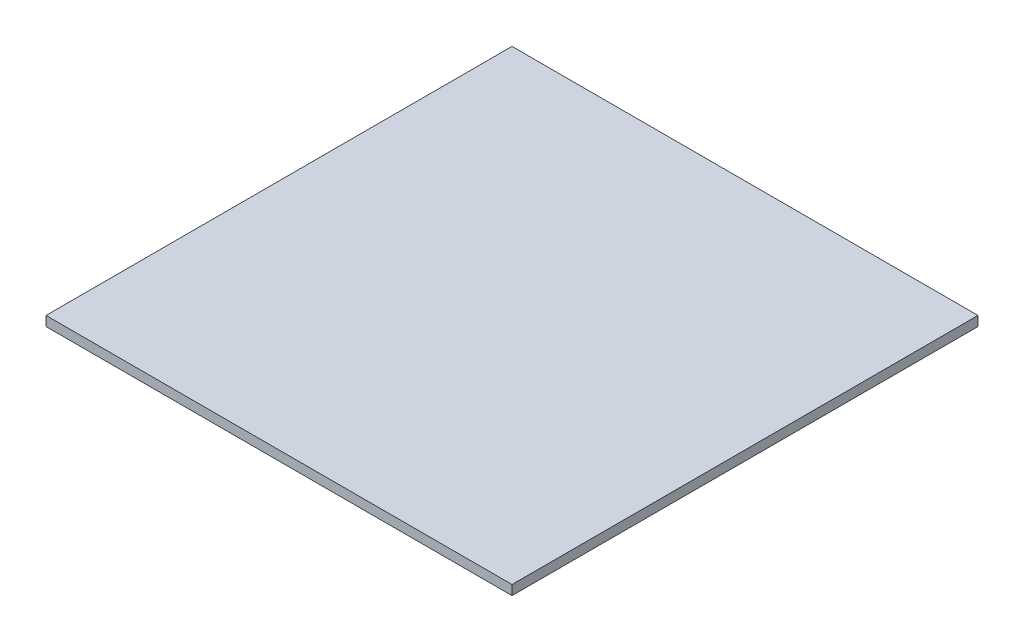
from build123d import *

# Parameters (mm, degrees)
SKETCH2_R           = 60
BOSS_EXTRUDE1_DEPTH = 36
SKETCH3_W           = 290
SKETCH3_H           = 290
BOSS_EXTRUDE2_DEPTH = 6


with BuildPart() as part:
    # Sketch2 → Boss-Extrude1 (new body)
    with BuildSketch(Plane(origin=(0, 0, 0), x_dir=(1, 0, 0), z_dir=(0, 1, 0))):
        Circle(SKETCH2_R)
    extrude(amount=BOSS_EXTRUDE1_DEPTH)

    # Sketch3 → Boss-Extrude2 (add)
    with BuildSketch(Plane(origin=(0, 36, 0), x_dir=(1, 0, 0), z_dir=(0, 1, 0))):
        Rectangle(SKETCH3_W, SKETCH3_H)
    extrude(amount=BOSS_EXTRUDE2_DEPTH)


solid = part.part
